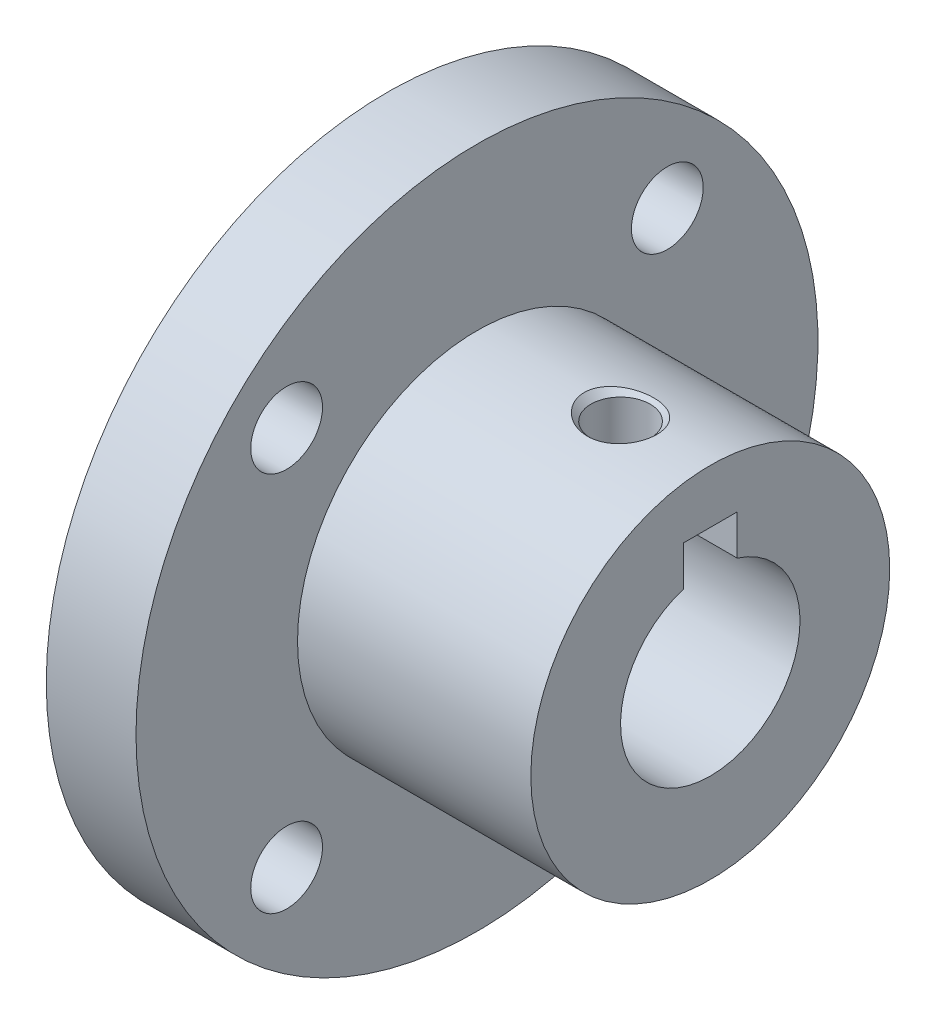
from build123d import *

# Parameters (mm, degrees)
SKETCH1_R                   = 10
SMALLRING_DEPTH             = 13
SKETCH4_R                   = 19
SKETCH4_R_2                 = 2
BIGRING_DEPTH               = 5
M4_TAPPED_HOLE1_D           = 3.3
M4_TAPPED_HOLE1_DEPTH       = 10.1
M4_TAPPED_HOLE1_CSINK_D     = 4.05
M4_TAPPED_HOLE1_CSINK_ANGLE = 90
M4_TAPPED_HOLE1_TIP         = 0.991420021
SKETCH42_R                  = 5
MOTOR_SHAFT_HOLE_DEPTH      = 20
SKETCH43_W                  = 3
SKETCH43_H                  = 4
KEYWAY_DEPTH                = 18


with BuildPart() as part:
    # Sketch1 → SmallRing (new body)
    with BuildSketch(Plane(origin=(0, 0, 0), x_dir=(0, 0, -1), z_dir=(1, 0, 0))):
        Circle(SKETCH1_R)
    extrude(amount=SMALLRING_DEPTH)

    # Sketch4 → BigRing (add)
    with BuildSketch(Plane.ZY):
        Circle(SKETCH4_R)
        with Locations((-10.606601718, 10.606601718)):
            Circle(SKETCH4_R_2, mode=Mode.SUBTRACT)
        with Locations((10.606601718, 10.606601718)):
            Circle(SKETCH4_R_2, mode=Mode.SUBTRACT)
        with Locations((10.606601718, -10.606601718)):
            Circle(SKETCH4_R_2, mode=Mode.SUBTRACT)
        with Locations((-10.606601718, -10.606601718)):
            Circle(SKETCH4_R_2, mode=Mode.SUBTRACT)
    extrude(amount=BIGRING_DEPTH)

    # M4 Tapped Hole1
    with Locations(Plane(origin=(8, 10, 0), x_dir=(1, 0, 0), z_dir=(0, 1, 0))):
        with Locations((0, 0)):
            CounterSinkHole(M4_TAPPED_HOLE1_D / 2, M4_TAPPED_HOLE1_CSINK_D / 2, depth=M4_TAPPED_HOLE1_DEPTH, counter_sink_angle=M4_TAPPED_HOLE1_CSINK_ANGLE)
            with Locations((0, 0, -(M4_TAPPED_HOLE1_DEPTH + M4_TAPPED_HOLE1_TIP / 2))):  # 118° drill point
                Cone(0, M4_TAPPED_HOLE1_D / 2, M4_TAPPED_HOLE1_TIP, mode=Mode.SUBTRACT)

    # Sketch42 → Motor Shaft Hole (cut)
    with BuildSketch(Plane(origin=(13, 0, 0), x_dir=(0, 0, -1), z_dir=(1, 0, 0))):
        Circle(SKETCH42_R)
    extrude(amount=-MOTOR_SHAFT_HOLE_DEPTH, mode=Mode.SUBTRACT)

    # Sketch43 → Keyway (cut)
    with BuildSketch(Plane(origin=(13, 0, 0), x_dir=(0, 0, -1), z_dir=(1, 0, 0))):
        with Locations((0, 5)):
            Rectangle(SKETCH43_W, SKETCH43_H)
    extrude(amount=-KEYWAY_DEPTH, mode=Mode.SUBTRACT)


solid = part.part
